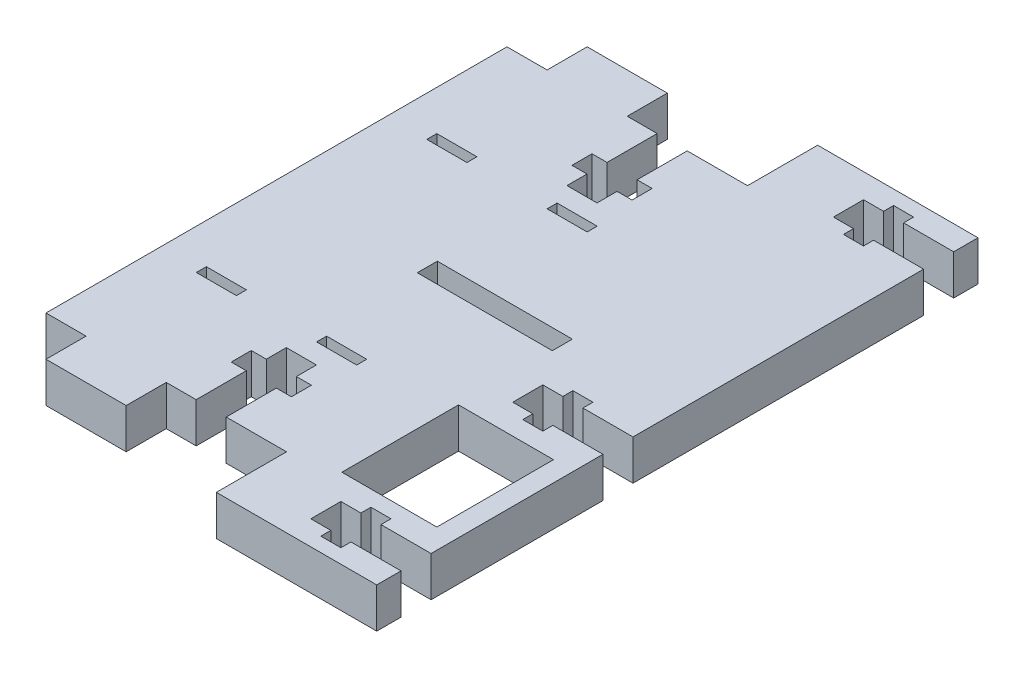
from build123d import *

# Parameters (mm, degrees)
BOSS_EXTRUDE1_DEPTH = 6.35
SKETCH2_W           = 6.35
SKETCH2_H           = 1.5875
CUT_EXTRUDE1_DEPTH  = 6.35
BOSS_EXTRUDE2_START = -6.35
SKETCH4_W           = 24.326613467
SKETCH4_H           = 69.85
BOSS_EXTRUDE2_DEPTH = 6.35
SKETCH5_W           = 25.4
SKETCH5_H           = 3.175
CUT_EXTRUDE3_DEPTH  = 6.35
SKETCH7_W           = 19.923596682
SKETCH7_H           = 95.25
CUT_EXTRUDE4_DEPTH  = 6.35
SKETCH8_W           = 15.043251586
SKETCH8_H           = 69.85
CUT_EXTRUDE5_DEPTH  = 6.35
SKETCH9_W           = 3.175
SKETCH9_H           = 95.25
BOSS_EXTRUDE3_DEPTH = 6.35
SKETCH10_W          = 17.539756693
SKETCH10_H          = 95.25
CUT_EXTRUDE7_DEPTH  = 6.35
SKETCH3_W           = 4.7625
SKETCH3_H           = 14.2875
SKETCH3_W_2         = 9.525
SKETCH3_H_2         = 3.175
CUT_EXTRUDE8_DEPTH  = 6.35
SKETCH11_W          = 14.2875
SKETCH11_H          = 4.7625
SKETCH11_W_2        = 3.175
SKETCH11_H_2        = 7.9375
CUT_EXTRUDE9_DEPTH  = 6.35
SKETCH13_W          = 15.043251586
SKETCH13_H          = 51.369192813
BOSS_EXTRUDE4_DEPTH = 6.35
SKETCH14_W          = 14.2875
SKETCH14_H          = 4.7625
SKETCH14_W_2        = 3.175
SKETCH14_H_2        = 7.9375
CUT_EXTRUDE10_DEPTH = 6.35


with BuildPart() as part:
    # Sketch1 → Boss-Extrude1 (new body)
    with BuildSketch(Plane(origin=(0, 0, 0), x_dir=(1, 0, 0), z_dir=(0, 1, 0))):
        Polygon((38.1, 65.0875), (84.214756693, 65.0875), (84.214756693, -30.1625), (38.1, -30.1625), (38.1, -19.05), (19.05, -19.05), (19.05, -25.4), (6.35, -25.4), (6.35, -19.05), (0, -19.05), (0, 0), (0, 34.925), (0, 53.975), (6.35, 53.975), (6.35, 60.325), (19.05, 60.325), (19.05, 53.975), (38.1, 53.975), align=None)
        Polygon((38.1, 34.925), (44.45, 38.591174209), (44.45, 52.3875), (74.689756693, 52.3875), (77.864756693, 50.8), (77.864756693, -15.875), (74.689756693, -17.4625), (44.45, -17.4625), (44.45, -3.666174209), (38.1, 0), align=None, mode=Mode.SUBTRACT)
    extrude(amount=BOSS_EXTRUDE1_DEPTH)

    # Sketch2 → Cut-Extrude1 (cut)
    with BuildSketch(Plane(origin=(0, 6.35, 0), x_dir=(1, 0, 0), z_dir=(0, 1, 0))):
        with Locations((9.525, 35.71875)):
            Rectangle(SKETCH2_W, SKETCH2_H)
        with Locations((9.525, -0.79375)):
            Rectangle(SKETCH2_W, SKETCH2_H)
        with Locations((28.575, 35.71875)):
            Rectangle(SKETCH2_W, SKETCH2_H)
        with Locations((28.575, -0.79375)):
            Rectangle(SKETCH2_W, SKETCH2_H)
    extrude(amount=-CUT_EXTRUDE1_DEPTH, mode=Mode.SUBTRACT)

    # Sketch4 → Boss-Extrude2 (add)
    with BuildSketch(Plane(origin=(0, 6.35, 0), x_dir=(1, 0, 0), z_dir=(0, 1, 0)).offset(BOSS_EXTRUDE2_START)):
        with Locations((49.82644996, 17.4625)):
            Rectangle(SKETCH4_W, SKETCH4_H)
    extrude(amount=BOSS_EXTRUDE2_DEPTH)

    # Sketch5 → Cut-Extrude3 (cut)
    with BuildSketch(Plane(origin=(0, 6.35, 0), x_dir=(1, 0, 0), z_dir=(0, 1, 0))):
        with Locations((61.989756693, 17.4625)):
            Rectangle(SKETCH5_W, SKETCH5_H)
        with Locations((36.589756693, 17.4625)):
            Rectangle(SKETCH5_W, SKETCH5_H)
    extrude(amount=-CUT_EXTRUDE3_DEPTH, mode=Mode.SUBTRACT)

    # Sketch7 → Cut-Extrude4 (cut)
    with BuildSketch(Plane(origin=(0, 6.35, 0), x_dir=(1, 0, 0), z_dir=(0, 1, 0))):
        with Locations((91.001555034, 17.4625)):
            Rectangle(SKETCH7_W, SKETCH7_H)
    extrude(amount=-CUT_EXTRUDE4_DEPTH, mode=Mode.SUBTRACT)

    # Sketch8 → Cut-Extrude5 (cut)
    with BuildSketch(Plane.XZ):
        with Locations((52.803374207, -17.4625)):
            Rectangle(SKETCH8_W, SKETCH8_H)
    extrude(amount=-CUT_EXTRUDE5_DEPTH, mode=Mode.SUBTRACT)

    # Sketch9 → Boss-Extrude3 (add)
    with BuildSketch(Plane.XZ):
        with Locations((61.9125, -17.4625)):
            Rectangle(SKETCH9_W, SKETCH9_H)
    extrude(amount=-BOSS_EXTRUDE3_DEPTH)

    # Sketch10 → Cut-Extrude7 (cut)
    with BuildSketch(Plane.XZ):
        with Locations((72.269878347, -17.4625)):
            Rectangle(SKETCH10_W, SKETCH10_H)
    extrude(amount=-CUT_EXTRUDE7_DEPTH, mode=Mode.SUBTRACT)

    # Sketch3 → Cut-Extrude8 (cut)
    with BuildSketch(Plane(origin=(0, 6.35, 0), x_dir=(1, 0, 0), z_dir=(0, 1, 0))):
        with Locations((26.168267374, 46.83125)):
            Rectangle(SKETCH3_W, SKETCH3_H)
        with Locations((26.168267374, 44.45)):
            Rectangle(SKETCH3_W_2, SKETCH3_H_2)
        with Locations((26.168267374, -9.525)):
            Rectangle(SKETCH3_W_2, SKETCH3_H_2)
        with Locations((26.168267374, -11.90625)):
            Rectangle(SKETCH3_W, SKETCH3_H)
    extrude(amount=-CUT_EXTRUDE8_DEPTH, mode=Mode.SUBTRACT)

    # Sketch11 → Cut-Extrude9 (cut)
    with BuildSketch(Plane.XZ):
        with Locations((56.35625, 23.932056084)):
            Rectangle(SKETCH11_W, SKETCH11_H)
        with Locations((53.975, 23.932056084)):
            Rectangle(SKETCH11_W_2, SKETCH11_H_2)
        with Locations((53.975, -58.857056084)):
            Rectangle(SKETCH11_W_2, SKETCH11_H_2)
        with Locations((56.35625, -58.857056084)):
            Rectangle(SKETCH11_W, SKETCH11_H)
    extrude(amount=-CUT_EXTRUDE9_DEPTH, mode=Mode.SUBTRACT)

    # Sketch13 → Boss-Extrude4 (add)
    with BuildSketch(Plane.XZ):
        with Locations((52.803374207, -26.702903594)):
            Rectangle(SKETCH13_W, SKETCH13_H)
    extrude(amount=-BOSS_EXTRUDE4_DEPTH)

    # Sketch14 → Cut-Extrude10 (cut)
    with BuildSketch(Plane.XZ):
        with Locations((56.35625, -8.057056084)):
            Rectangle(SKETCH14_W, SKETCH14_H)
        with Locations((53.975, -8.057056084)):
            Rectangle(SKETCH14_W_2, SKETCH14_H_2)
    extrude(amount=-CUT_EXTRUDE10_DEPTH, mode=Mode.SUBTRACT)


solid = part.part
